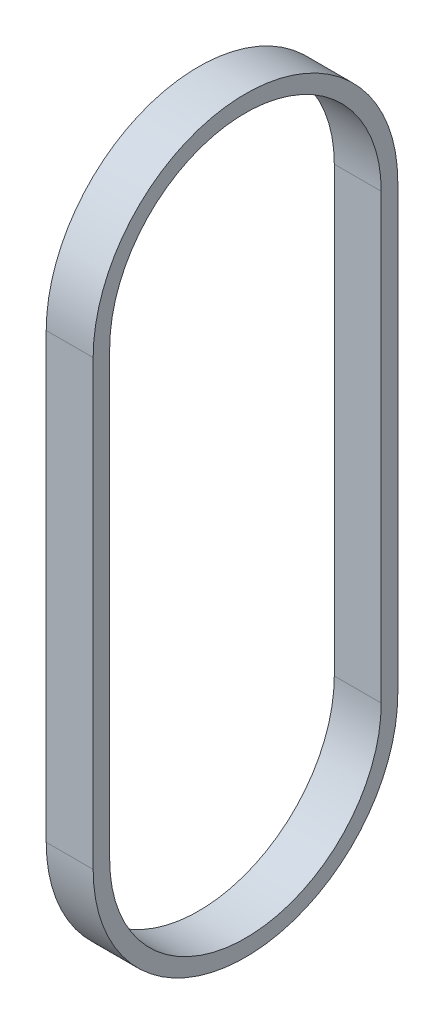
from build123d import *

# Parameters (mm, degrees)
BOSS_EXTRUDE1_DEPTH = 9


with BuildPart() as part:
    # Sketch1 → Boss-Extrude1 (new body)
    with BuildSketch(Plane(origin=(0, 0, 0), x_dir=(0, 0, -1), z_dir=(1, 0, 0))):
        with BuildLine():
            Line((-29.21, 85.0011), (-29.21, 0))
            ThreePointArc((-29.21, 0), (0, -29.21), (29.21, 0))
            Line((29.21, 0), (29.21, 85.0011))
            ThreePointArc((29.21, 85.0011), (0, 114.2111), (-29.21, 85.0011))
        make_face()
        with BuildLine():
            Line((26.035, 85.0011), (26.035, 0))
            ThreePointArc((26.035, 0), (0, -26.035), (-26.035, 0))
            Line((-26.035, 0), (-26.035, 85.0011))
            ThreePointArc((-26.035, 85.0011), (0, 111.0361), (26.035, 85.0011))
        make_face(mode=Mode.SUBTRACT)
    extrude(amount=BOSS_EXTRUDE1_DEPTH)


solid = part.part
